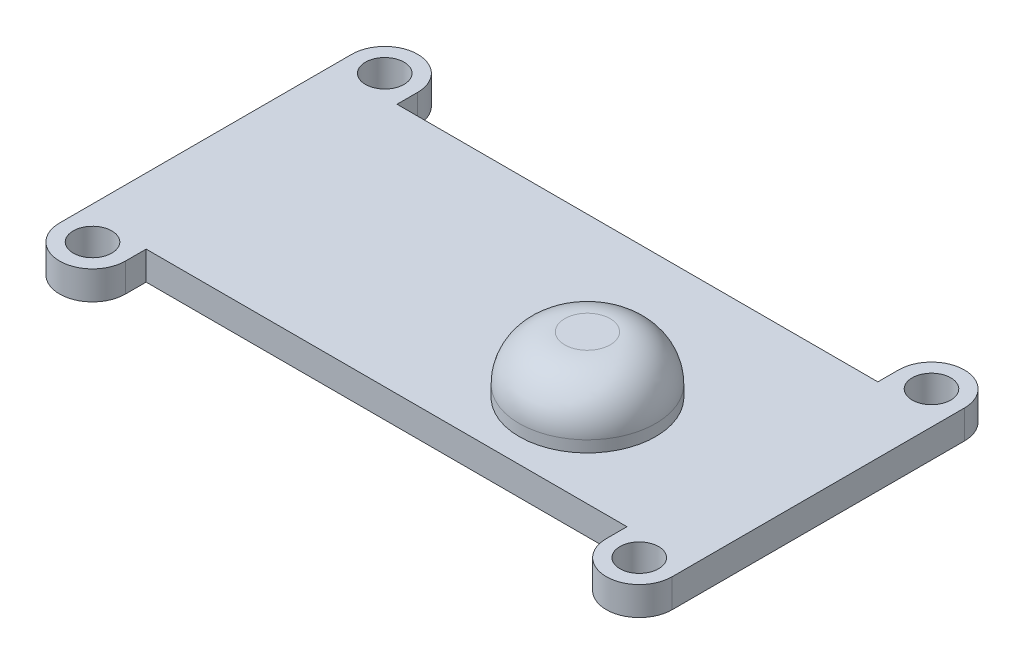
from build123d import *

# Parameters (mm, degrees)
SKETCH1_R           = 1.0795
BOSS_EXTRUDE1_DEPTH = 0.8001
SKETCH2_R           = 3.81
BOSS_EXTRUDE2_DEPTH = 3.175
FILLET1_R           = 2.54


with BuildPart() as part:
    # Sketch1 → Boss-Extrude1 (new body, symmetric)
    with BuildSketch(Plane(origin=(0, 0, 0), x_dir=(1, 0, 0), z_dir=(0, 1, 0))):
        with BuildLine():
            Line((-13.4366, -7.0104), (13.4366, -7.0104))
            Line((13.4366, -7.0104), (13.4366, -8.1661))
            ThreePointArc((13.4366, -8.1661), (15.2781, -10.0076), (17.1196, -8.1661))
            Line((17.1196, -8.1661), (17.1196, -7.0104))
            Line((17.1196, -7.0104), (17.1196, 7.0104))
            Line((17.1196, 7.0104), (17.1196, 8.1661))
            ThreePointArc((17.1196, 8.1661), (15.2781, 10.0076), (13.4366, 8.1661))
            Line((13.4366, 8.1661), (13.4366, 7.0104))
            Line((13.4366, 7.0104), (-13.4366, 7.0104))
            Line((-13.4366, 7.0104), (-13.4366, 8.1661))
            ThreePointArc((-13.4366, 8.1661), (-15.2781, 10.0076), (-17.1196, 8.1661))
            Line((-17.1196, 8.1661), (-17.1196, 7.0104))
            Line((-17.1196, 7.0104), (-17.1196, -7.0104))
            Line((-17.1196, -7.0104), (-17.1196, -8.1661))
            ThreePointArc((-17.1196, -8.1661), (-15.2781, -10.0076), (-13.4366, -8.1661))
            Line((-13.4366, -8.1661), (-13.4366, -7.0104))
        make_face()
        with Locations((-15.2781, 8.1661)):
            Circle(SKETCH1_R, mode=Mode.SUBTRACT)
        with Locations((-15.2781, -8.1661)):
            Circle(SKETCH1_R, mode=Mode.SUBTRACT)
        with Locations((15.2781, 8.1661)):
            Circle(SKETCH1_R, mode=Mode.SUBTRACT)
        with Locations((15.2781, -8.1661)):
            Circle(SKETCH1_R, mode=Mode.SUBTRACT)
    extrude(amount=BOSS_EXTRUDE1_DEPTH, both=True)

    # Sketch2 → Boss-Extrude2 (add)
    with BuildSketch(Plane(origin=(0, 0.8001, 0), x_dir=(1, 0, 0), z_dir=(0, 1, 0))):
        with Locations((6.0706, -1.8542)):
            Circle(SKETCH2_R)
    extrude(amount=BOSS_EXTRUDE2_DEPTH)

    # Fillet1
    fillet1_edges = [part.edges().sort_by_distance(p)[0] for p in [
        (2.2606, 3.9751, 1.8542),
    ]]
    fillet(fillet1_edges, radius=FILLET1_R)


solid = part.part
